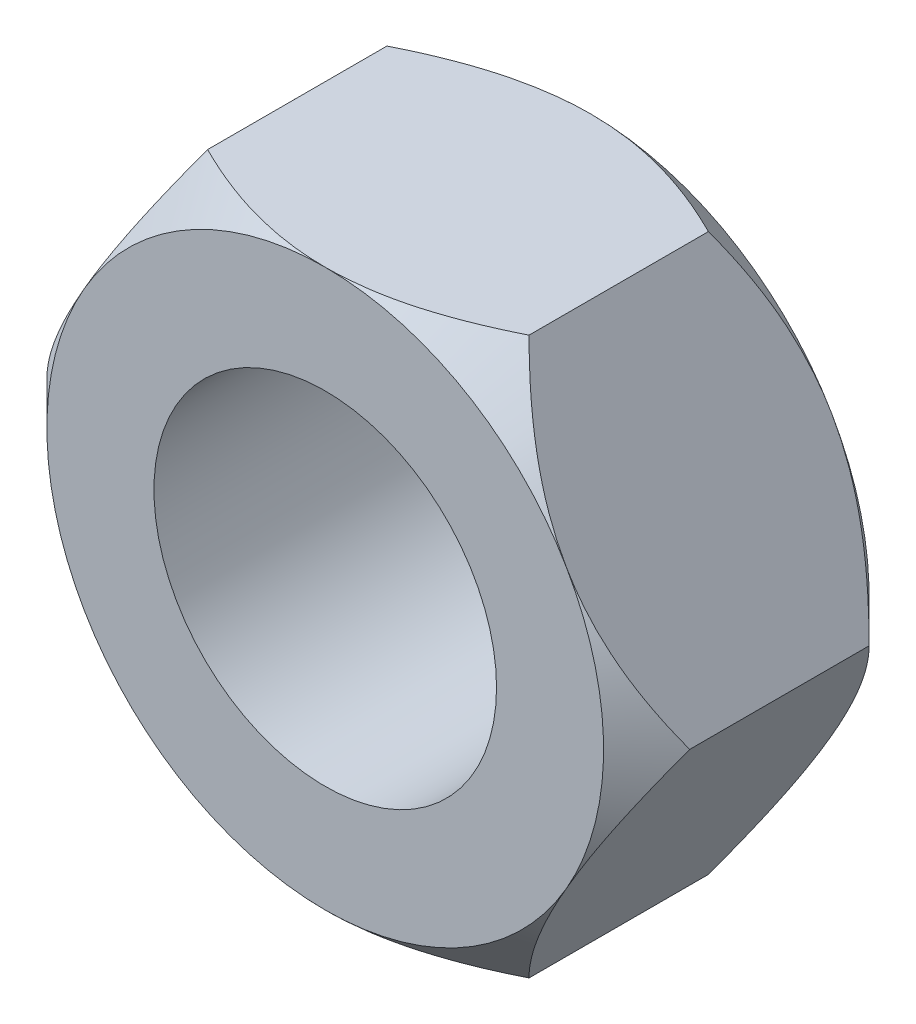
from build123d import *

# Parameters (mm, degrees)
ESBO_O1_R                = 4
RESSALTO_EXTRUS_O1_DEPTH = 6.2
ESBO_O2_OUTSIDE_W        = 33.572
ESBO_O2_OUTSIDE_H        = 31.56
ESBO_O2_OUTSIDE_R        = 6.5
CORTE_EXTRUS_O1_DEPTH    = 6.2
CORTE_EXTRUS_O1_TAPER    = 45
ESBO_O3_OUTSIDE_W        = 33.572
ESBO_O3_OUTSIDE_H        = 31.56
ESBO_O3_OUTSIDE_R        = 6.5
CORTE_EXTRUS_O2_DEPTH    = 6.2
CORTE_EXTRUS_O2_TAPER    = 45


with BuildPart() as part:
    # Esboço1 → Ressalto-extrusão1 (new body)
    with BuildSketch(Plane.XY):
        Polygon((3.75277675, -6.5), (7.505553499, 0), (3.75277675, 6.5), (-3.75277675, 6.5), (-7.505553499, 0), (-3.75277675, -6.5), align=None)
        Circle(ESBO_O1_R, mode=Mode.SUBTRACT)
    extrude(amount=RESSALTO_EXTRUS_O1_DEPTH)

    # Esboço2 outside → Corte-extrusão1 (cut)
    with BuildSketch(Plane.XY.offset(6.2)):
        Rectangle(ESBO_O2_OUTSIDE_W, ESBO_O2_OUTSIDE_H)
        Circle(ESBO_O2_OUTSIDE_R, mode=Mode.SUBTRACT)
    extrude(amount=-CORTE_EXTRUS_O1_DEPTH, taper=CORTE_EXTRUS_O1_TAPER, mode=Mode.SUBTRACT)

    # Esboço3 outside → Corte-extrusão2 (cut)
    with BuildSketch(Plane(origin=(0, 0, 0), x_dir=(-1, 0, 0), z_dir=(0, 0, -1))):
        Rectangle(ESBO_O3_OUTSIDE_W, ESBO_O3_OUTSIDE_H)
        Circle(ESBO_O3_OUTSIDE_R, mode=Mode.SUBTRACT)
    extrude(amount=-CORTE_EXTRUS_O2_DEPTH, taper=CORTE_EXTRUS_O2_TAPER, mode=Mode.SUBTRACT)


solid = part.part
